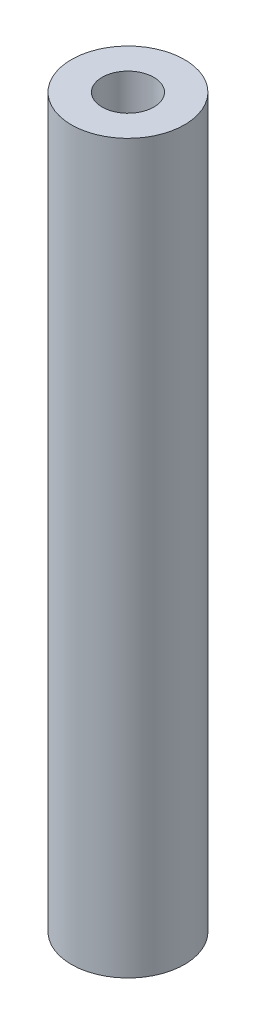
from build123d import *

# Parameters (mm, degrees)
SKETCH1_R           = 7
SKETCH1_R_2         = 3.2
BOSS_EXTRUDE1_DEPTH = 90


with BuildPart() as part:
    # Sketch1 → Boss-Extrude1 (new body)
    with BuildSketch(Plane(origin=(0, 0, 0), x_dir=(1, 0, 0), z_dir=(0, 1, 0))):
        Circle(SKETCH1_R)
        Circle(SKETCH1_R_2, mode=Mode.SUBTRACT)
    extrude(amount=BOSS_EXTRUDE1_DEPTH)


solid = part.part
